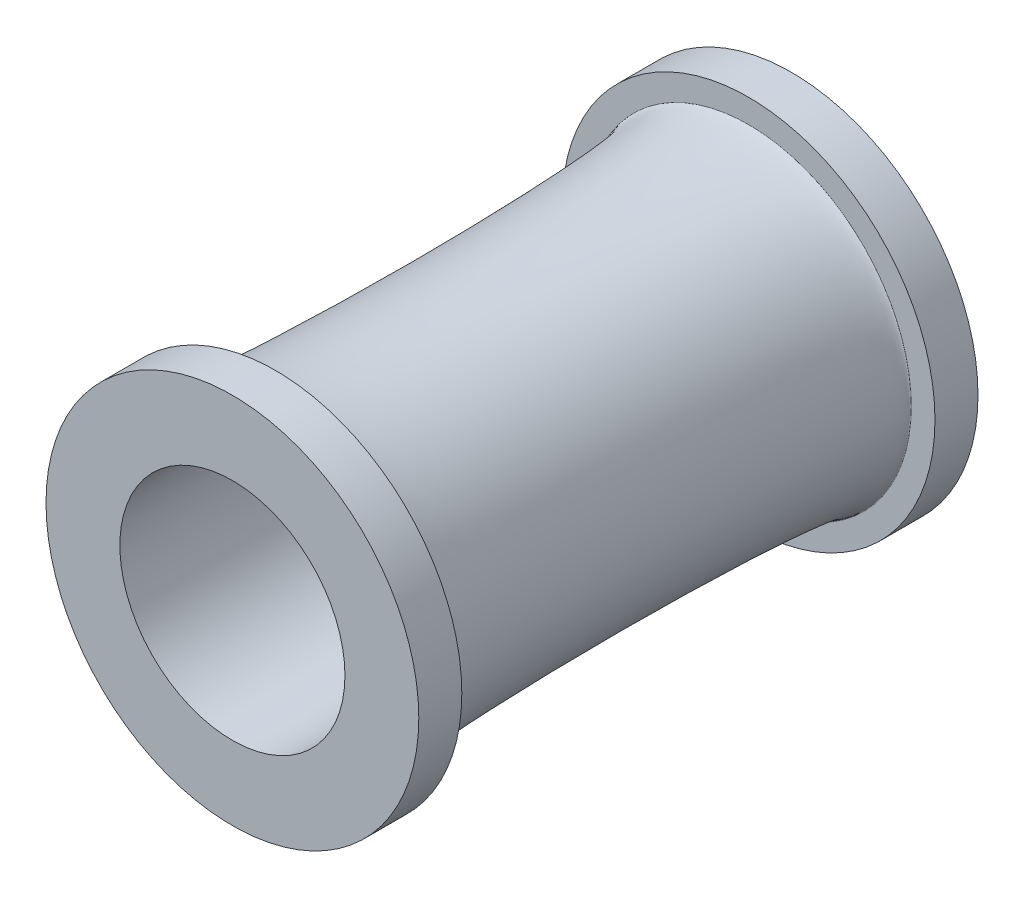
from build123d import *

# Parameters (mm, degrees)
SKETCH1_R           = 14.4145
SKETCH1_R_2         = 9.9695
BOSS_EXTRUDE1_DEPTH = 41.91
SKETCH2_R           = 19.05
SKETCH2_R_2         = 9.9695
BOSS_EXTRUDE2_DEPTH = 3.81
FILLET1_R           = 1.778
SKETCH3_RX          = 20.955
SKETCH3_RY          = 1.135862225
SKETCH4_R           = 19.05
SKETCH4_R_2         = 16.51
RIM_CUT_DEPTH       = 50.53


with BuildPart() as part:
    # Sketch1 → Boss-Extrude1 (new body)
    with BuildSketch(Plane.XY):
        Circle(SKETCH1_R)
        Circle(SKETCH1_R_2, mode=Mode.SUBTRACT)
    extrude(amount=BOSS_EXTRUDE1_DEPTH)

    # Sketch2 → Boss-Extrude2 (add)
    with BuildSketch(Plane.XY.offset(41.91)):
        Circle(SKETCH2_R)
        Circle(SKETCH2_R_2, mode=Mode.SUBTRACT)
    boss_extrude2 = extrude(amount=BOSS_EXTRUDE2_DEPTH)

    # Mirror1: Boss-Extrude2 across plane
    add(boss_extrude2.mirror(Plane.XY.offset(20.955)))

    # Fillet1
    fillet1_edges = [part.edges().sort_by_distance(p)[0] for p in [
        (-19.05, 0, 41.91),
        (-19.05, 0, 0),
    ]]
    fillet(fillet1_edges, radius=FILLET1_R)

    # Sketch3 → Cut-Revolve1 (revolve, cut)
    with BuildSketch(Plane(origin=(0, 0, 0), x_dir=(1, 0, 0), z_dir=(0, 1, 0))):
        with Locations(Location((-14.4145, -20.955), (0, 0, -90))):
            Ellipse(SKETCH3_RX, SKETCH3_RY)
    revolve(axis=Axis((0, 0, 45.72), (0, 0, -1)), mode=Mode.SUBTRACT)

    # Sketch4 → Rim_Cut (cut, through all)
    with BuildSketch(Plane(origin=(0, 0, -3.81), x_dir=(-1, 0, 0), z_dir=(0, 0, -1))):
        Circle(SKETCH4_R)
        Circle(SKETCH4_R_2, mode=Mode.SUBTRACT)
    extrude(amount=-RIM_CUT_DEPTH, mode=Mode.SUBTRACT)


solid = part.part
